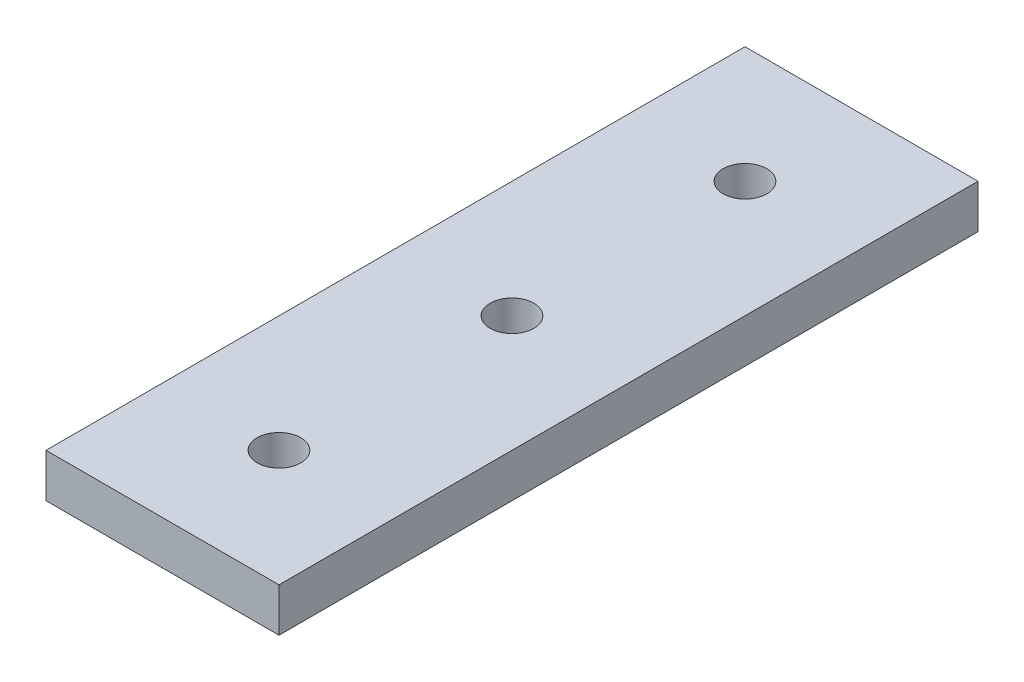
from build123d import *

# Parameters (mm, degrees)
SKETCH1_W           = 25.4
SKETCH1_H           = 76.2
BOSS_EXTRUDE1_DEPTH = 4.7625
SKETCH2_R           = 2.38125
CUT_EXTRUDE1_DEPTH  = 5.7625


with BuildPart() as part:
    # Sketch1 → Boss-Extrude1 (new body)
    with BuildSketch(Plane(origin=(0, 0, 0), x_dir=(1, 0, 0), z_dir=(0, 1, 0))):
        Rectangle(SKETCH1_W, SKETCH1_H)
    extrude(amount=BOSS_EXTRUDE1_DEPTH)

    # Sketch2 → Cut-Extrude1 (cut, through all)
    with BuildSketch(Plane(origin=(0, 4.7625, 0), x_dir=(1, 0, 0), z_dir=(0, 1, 0))):
        with Locations((0, 25.4)):
            Circle(SKETCH2_R)
        Circle(SKETCH2_R)
        with Locations((0, -25.4)):
            Circle(SKETCH2_R)
    extrude(amount=-CUT_EXTRUDE1_DEPTH, mode=Mode.SUBTRACT)


solid = part.part
